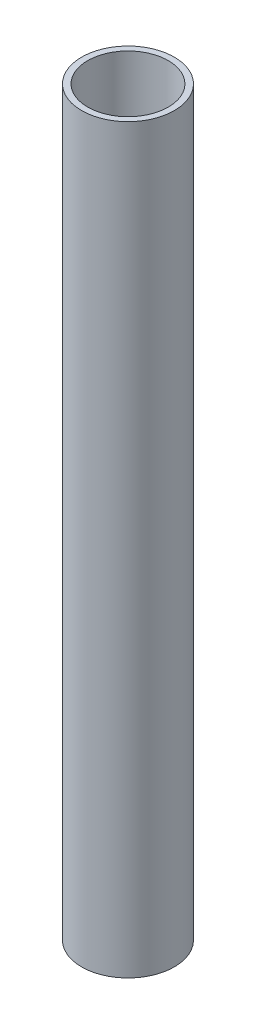
from build123d import *

# Parameters (mm, degrees)
SKETCH1_R           = 9.525
SKETCH1_R_2         = 8.2804
BOSS_EXTRUDE1_DEPTH = 152.4


with BuildPart() as part:
    # Sketch1 → Boss-Extrude1 (new body)
    with BuildSketch(Plane(origin=(0, 0, 0), x_dir=(1, 0, 0), z_dir=(0, 1, 0))):
        Circle(SKETCH1_R)
        Circle(SKETCH1_R_2, mode=Mode.SUBTRACT)
    extrude(amount=BOSS_EXTRUDE1_DEPTH)


solid = part.part
